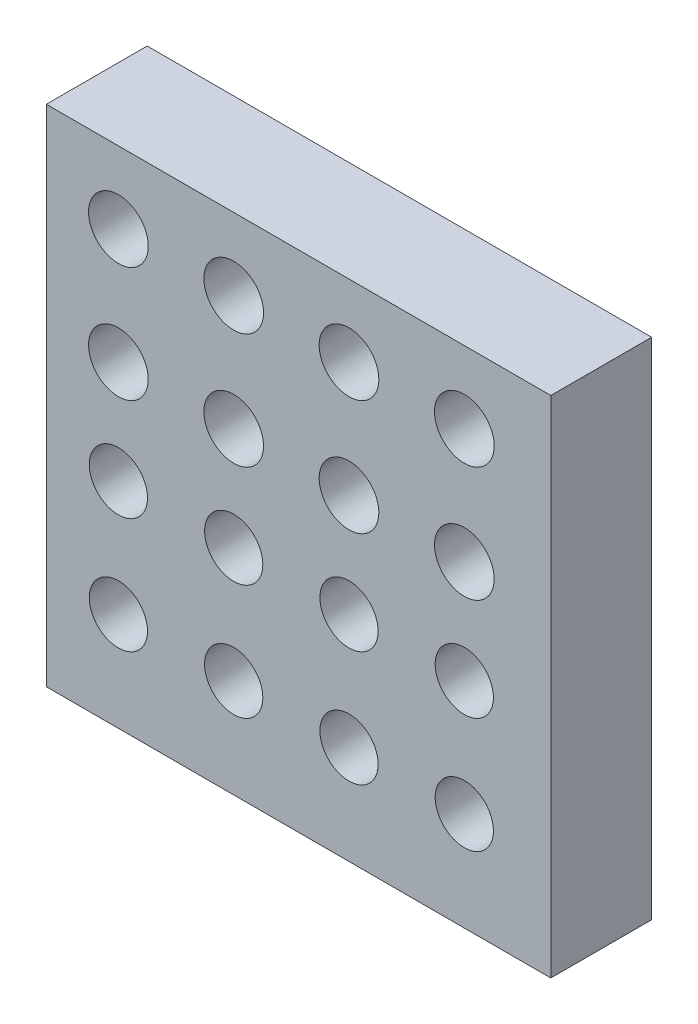
from build123d import *

# Parameters (mm, degrees)
SKETCH1_W           = 35
SKETCH1_H           = 35
BOSS_EXTRUDE1_DEPTH = 7
SKETCH2_R           = 2.07
SKETCH2_R_2         = 2.02
CUT_EXTRUDE1_DEPTH  = 5


with BuildPart() as part:
    # Sketch1 → Boss-Extrude1 (new body)
    with BuildSketch(Plane.XY):
        with Locations((17.5, -17.5)):
            Rectangle(SKETCH1_W, SKETCH1_H)
    extrude(amount=BOSS_EXTRUDE1_DEPTH)

    # Sketch2 → Cut-Extrude1 (cut)
    with BuildSketch(Plane.XY.offset(7)):
        with Locations((5, -5)):
            Circle(SKETCH2_R)
        with Locations((13, -5)):
            Circle(SKETCH2_R)
        with Locations((21, -5)):
            Circle(SKETCH2_R)
        with Locations((29, -5)):
            Circle(SKETCH2_R)
        with Locations((5, -13)):
            Circle(SKETCH2_R)
        with Locations((13, -13)):
            Circle(SKETCH2_R)
        with Locations((21, -13)):
            Circle(SKETCH2_R)
        with Locations((29, -13)):
            Circle(SKETCH2_R)
        with Locations((5, -20.149835752)):
            Circle(SKETCH2_R_2)
        with Locations((13, -20.149835752)):
            Circle(SKETCH2_R_2)
        with Locations((21, -20.149835752)):
            Circle(SKETCH2_R_2)
        with Locations((29, -20.149835752)):
            Circle(SKETCH2_R_2)
        with Locations((13, -28.149835752)):
            Circle(SKETCH2_R_2)
        with Locations((21, -28.149835752)):
            Circle(SKETCH2_R_2)
        with Locations((29, -28.149835752)):
            Circle(SKETCH2_R_2)
        with Locations((5, -28.149835752)):
            Circle(SKETCH2_R_2)
    extrude(amount=-CUT_EXTRUDE1_DEPTH, mode=Mode.SUBTRACT)


solid = part.part
